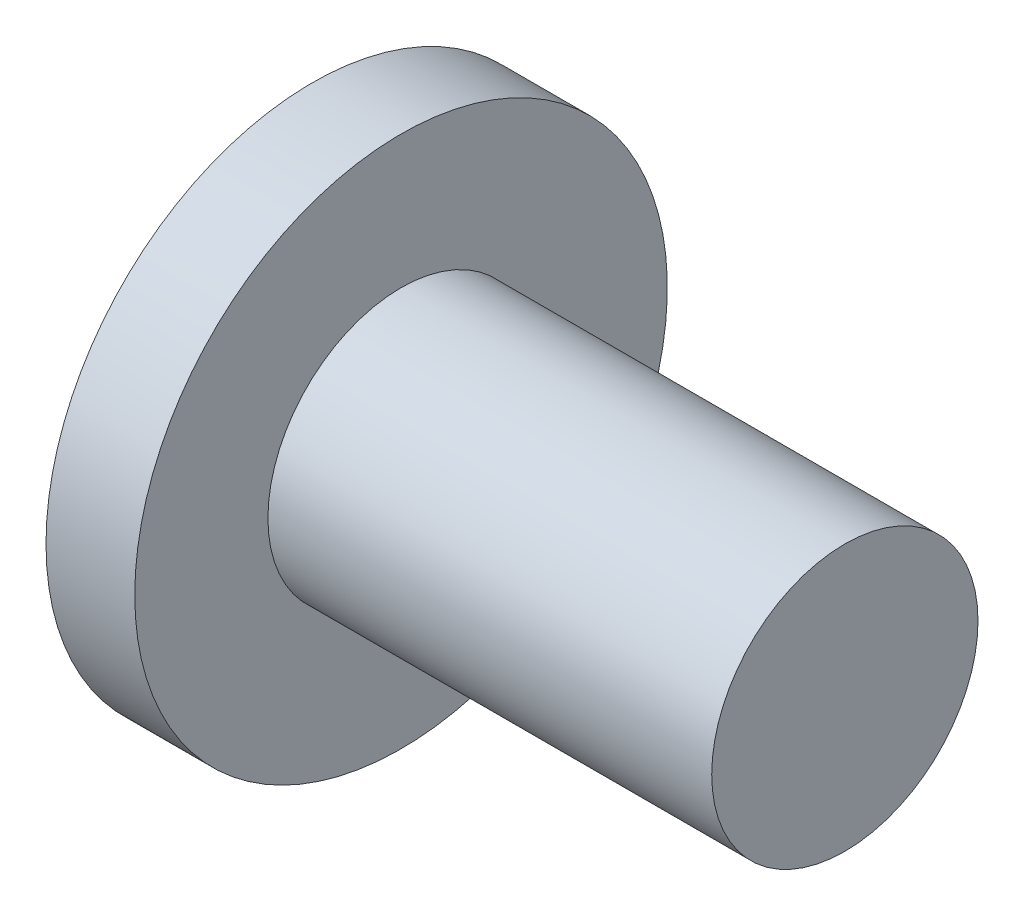
from build123d import *


with BuildPart() as part:
    # Çizim1 → Döndür1 (revolve)
    with BuildSketch(Plane.XY):
        Polygon((0, 0), (0, 6), (2, 6), (2, 3), (12, 3), (12, 0), align=None)
    revolve(axis=Axis((-21.47027027, 0, 0), (1, 0, 0)))


solid = part.part
